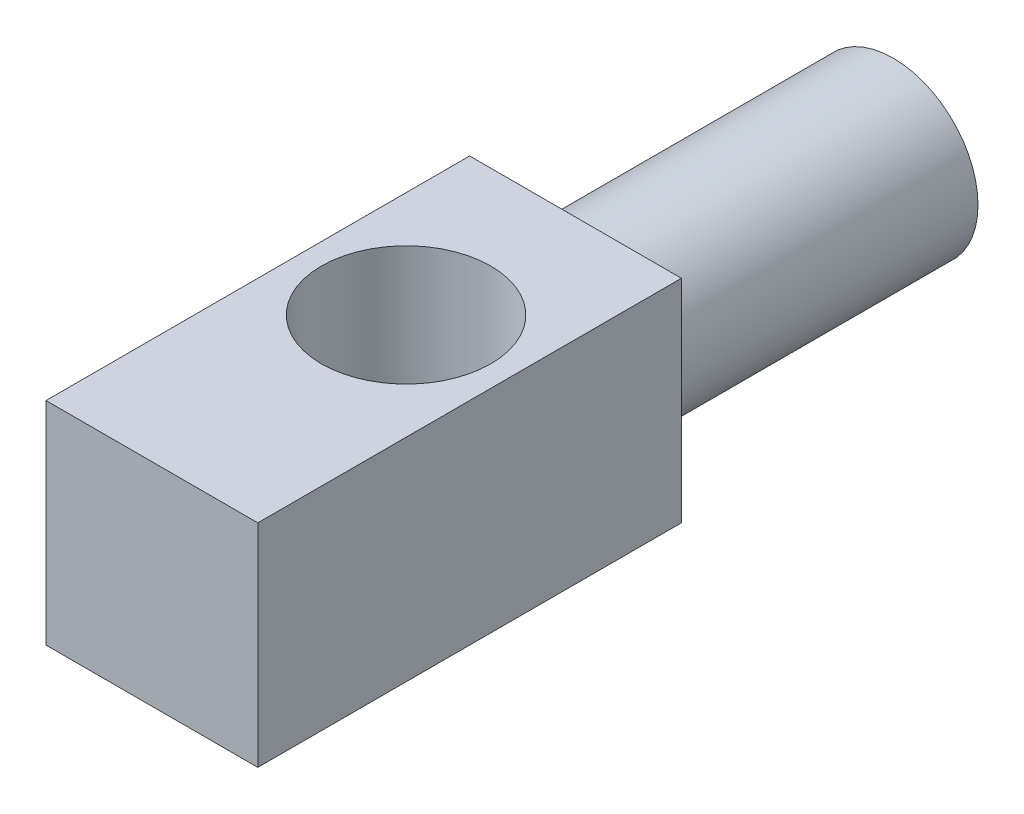
from build123d import *

# Parameters (mm, degrees)
CROQUIS1_W              = 50
CROQUIS1_H              = 100
CROQUIS1_R              = 20
SALIENTE_EXTRUIR1_DEPTH = 50
CROQUIS2_R              = 20
SALIENTE_EXTRUIR2_DEPTH = 75


with BuildPart() as part:
    # Croquis1 → Saliente-Extruir1 (new body)
    with BuildSketch(Plane(origin=(0, 0, 0), x_dir=(1, 0, 0), z_dir=(0, 1, 0))):
        with Locations((0, -10)):
            Rectangle(CROQUIS1_W, CROQUIS1_H)
        Circle(CROQUIS1_R, mode=Mode.SUBTRACT)
    extrude(amount=SALIENTE_EXTRUIR1_DEPTH)

    # Croquis2 → Saliente-Extruir2 (add)
    with BuildSketch(Plane(origin=(0, 0, -40), x_dir=(-1, 0, 0), z_dir=(0, 0, -1))):
        with Locations((0, 25)):
            Circle(CROQUIS2_R)
    extrude(amount=SALIENTE_EXTRUIR2_DEPTH)


solid = part.part
